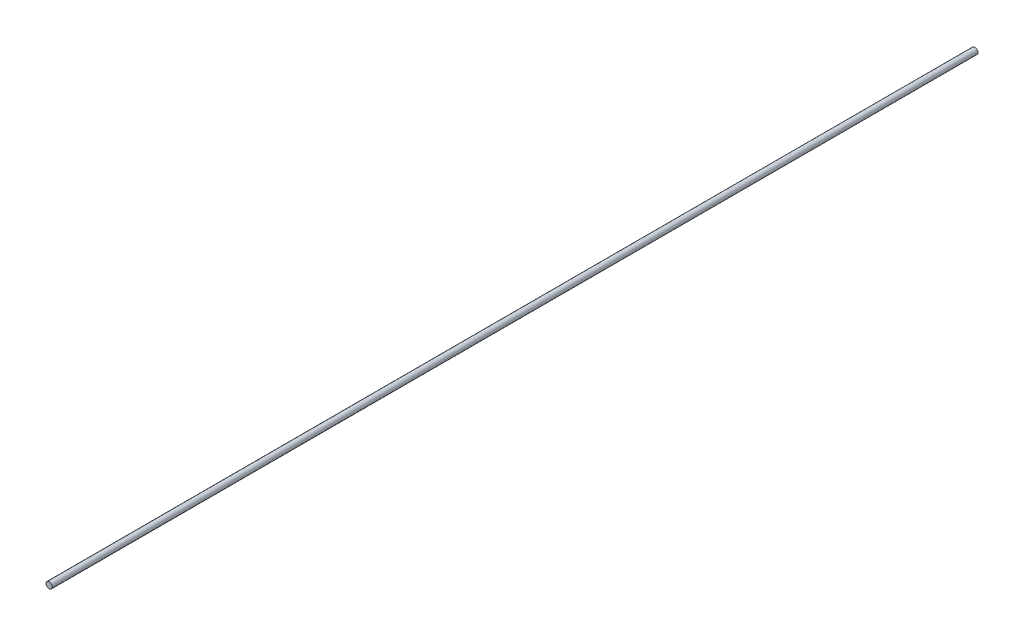
from build123d import *

# Parameters (mm, degrees)
SKETCH1_R           = 2
BOSS_EXTRUDE1_DEPTH = 600


with BuildPart() as part:
    # Sketch1 → Boss-Extrude1 (new body)
    with BuildSketch(Plane.XY):
        Circle(SKETCH1_R)
    extrude(amount=BOSS_EXTRUDE1_DEPTH)


solid = part.part
